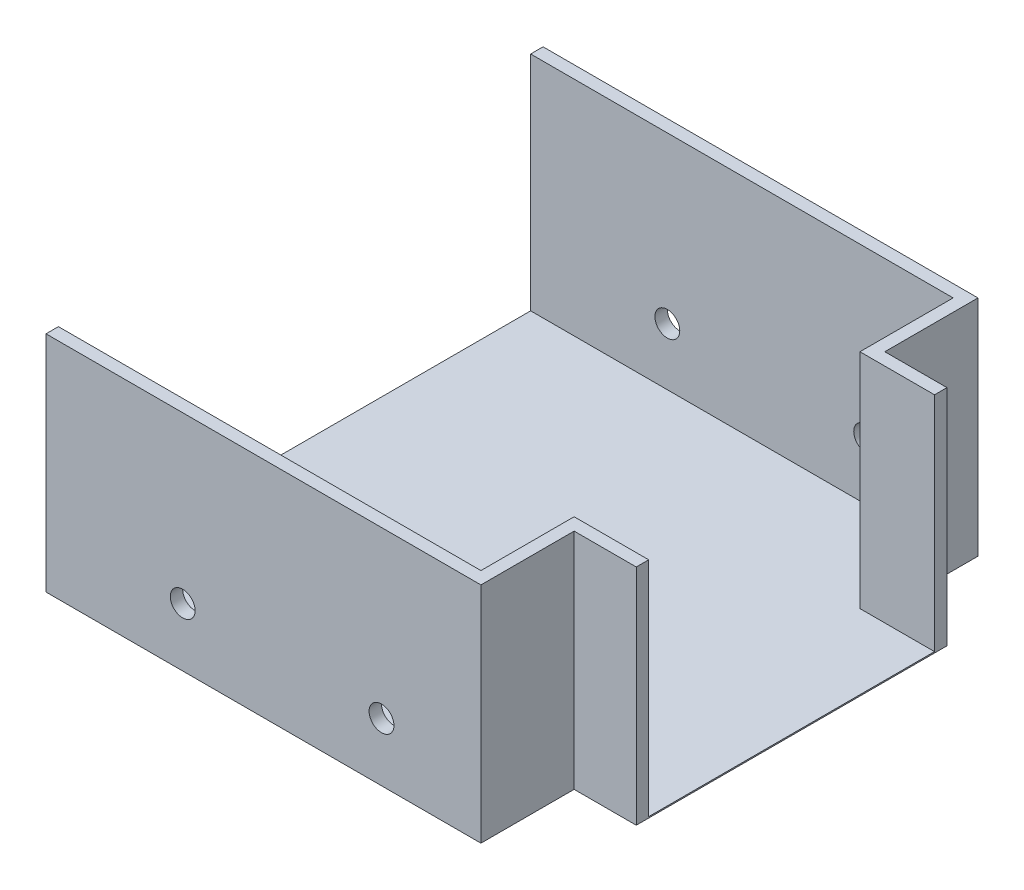
from build123d import *

# Parameters (mm, degrees)
SKETCH1_W           = 350
SKETCH1_H           = 400
SKETCH1_W_2         = 50
SKETCH1_H_2         = 250
BOSS_EXTRUDE1_DEPTH = 180
CUT_EXTRUDE1_DEPTH  = 179
SKETCH3_W           = 230
SKETCH3_H           = 179
CUT_EXTRUDE2_DEPTH  = 10
SKETCH4_W           = 380
SKETCH4_H           = 179
CUT_EXTRUDE3_DEPTH  = 10
SKETCH5_R           = 10
CUT_EXTRUDE4_DEPTH  = 401


with BuildPart() as part:
    # Sketch1 → Boss-Extrude1 (new body)
    with BuildSketch(Plane(origin=(0, 0, 0), x_dir=(1, 0, 0), z_dir=(0, 1, 0))):
        Rectangle(SKETCH1_W, SKETCH1_H)
        with Locations((200, 0)):
            Rectangle(SKETCH1_W_2, SKETCH1_H_2)
    extrude(amount=BOSS_EXTRUDE1_DEPTH)

    # Sketch2 → Cut-Extrude1 (cut)
    with BuildSketch(Plane(origin=(0, 180, 0), x_dir=(1, 0, 0), z_dir=(0, 1, 0))):
        Polygon((215, 115), (165, 115), (165, 190), (-165, 190), (-165, -190), (165, -190), (165, -115), (215, -115), align=None)
    extrude(amount=-CUT_EXTRUDE1_DEPTH, mode=Mode.SUBTRACT)

    # Sketch3 → Cut-Extrude2 (cut)
    with BuildSketch(Plane.ZY.offset(-215)):
        with Locations((0, 90.5)):
            Rectangle(SKETCH3_W, SKETCH3_H)
    extrude(amount=-CUT_EXTRUDE2_DEPTH, mode=Mode.SUBTRACT)

    # Sketch4 → Cut-Extrude3 (cut)
    with BuildSketch(Plane(origin=(-165, 0, 0), x_dir=(0, 0, -1), z_dir=(1, 0, 0))):
        with Locations((0, 90.5)):
            Rectangle(SKETCH4_W, SKETCH4_H)
    extrude(amount=-CUT_EXTRUDE3_DEPTH, mode=Mode.SUBTRACT)

    # Sketch5 → Cut-Extrude4 (cut, through all)
    with BuildSketch(Plane.XY.offset(200)):
        with Locations((95, 47)):
            Circle(SKETCH5_R)
        with Locations((-65, 47)):
            Circle(SKETCH5_R)
    extrude(amount=-CUT_EXTRUDE4_DEPTH, mode=Mode.SUBTRACT)


solid = part.part
